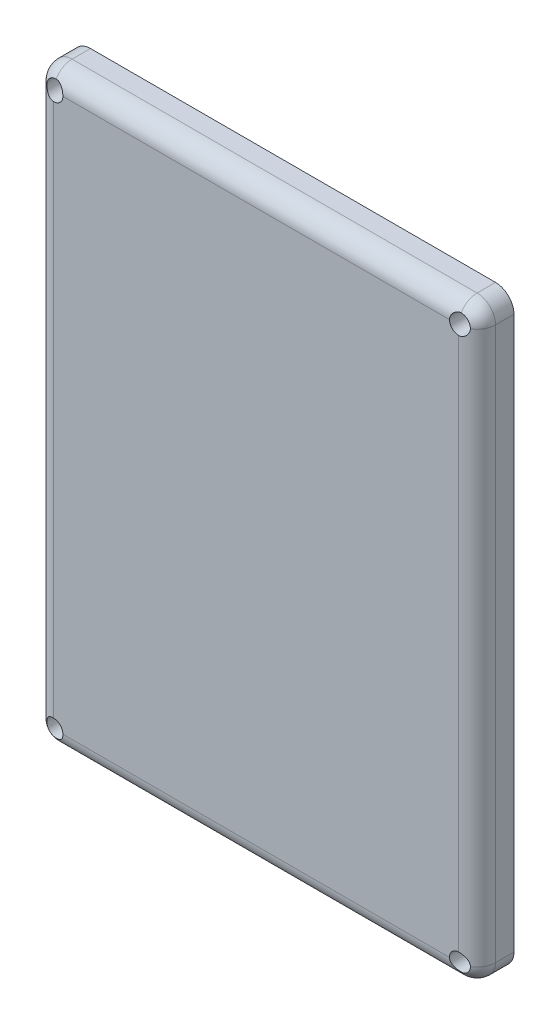
from build123d import *

# Parameters (mm, degrees)
SKETCH1_W           = 120
SKETCH1_H           = 160
BOSS_EXTRUDE1_DEPTH = 10
SKETCH2_W           = 100
SKETCH2_H           = 140
CUT_EXTRUDE1_DEPTH  = 5
FILLET1_R           = 5
FILLET2_R           = 5
FILLET3_R           = 5
SKETCH3_R           = 2.5
CUT_EXTRUDE2_DEPTH  = 5
SKETCH4_R           = 2.5
CUT_EXTRUDE3_DEPTH  = 5
SKETCH5_R           = 2.5
CUT_EXTRUDE4_DEPTH  = 5
SKETCH6_R           = 1.5
CUT_EXTRUDE5_DEPTH  = 10


with BuildPart() as part:
    # Sketch1 → Boss-Extrude1 (new body)
    with BuildSketch(Plane.XY):
        with Locations((60, -80)):
            Rectangle(SKETCH1_W, SKETCH1_H)
    extrude(amount=BOSS_EXTRUDE1_DEPTH)

    # Sketch2 → Cut-Extrude1 (cut)
    with BuildSketch(Plane(origin=(0, 0, 0), x_dir=(-1, 0, 0), z_dir=(0, 0, -1))):
        with Locations((-60, -80)):
            Rectangle(SKETCH2_W, SKETCH2_H)
    extrude(amount=-CUT_EXTRUDE1_DEPTH, mode=Mode.SUBTRACT)

    # Fillet1
    fillet1_edges = [part.edges().sort_by_distance(p)[0] for p in [
        (10, -10, 2.5),
    ]]
    fillet(fillet1_edges, radius=FILLET1_R)

    # Fillet2
    fillet2_edges = [part.edges().sort_by_distance(p)[0] for p in [
        (110, -150, 2.5),
        (110, -10, 2.5),
        (10, -150, 2.5),
    ]]
    fillet(fillet2_edges, radius=FILLET2_R)

    # Fillet3
    fillet3_edges = [part.edges().sort_by_distance(p)[0] for p in [
        (120, -80, 10),
        (60, 0, 10),
        (0, -80, 10),
        (60, -160, 10),
        (0, 0, 5),
        (120, 0, 5),
        (120, -160, 5),
        (0, -160, 5),
    ]]
    fillet(fillet3_edges, radius=FILLET3_R)

    # Sketch3 → Cut-Extrude2 (cut)
    with BuildSketch(Plane.XY.offset(10)):
        with Locations((115, -5)):
            Circle(SKETCH3_R)
    extrude(amount=-CUT_EXTRUDE2_DEPTH, mode=Mode.SUBTRACT)

    # Sketch4 → Cut-Extrude3 (cut)
    with BuildSketch(Plane.XY.offset(10)):
        with Locations((5, -5)):
            Circle(SKETCH4_R)
    extrude(amount=-CUT_EXTRUDE3_DEPTH, mode=Mode.SUBTRACT)

    # Sketch5 → Cut-Extrude4 (cut)
    with BuildSketch(Plane.XY.offset(10)):
        with Locations((5, -155)):
            Circle(SKETCH5_R)
        with Locations((115, -155)):
            Circle(SKETCH5_R)
    extrude(amount=-CUT_EXTRUDE4_DEPTH, mode=Mode.SUBTRACT)

    # Sketch6 → Cut-Extrude5 (cut)
    with BuildSketch(Plane.XY.offset(5)):
        with Locations((5, -5)):
            Circle(SKETCH6_R)
        with Locations((115, -5)):
            Circle(SKETCH6_R)
        with Locations((115, -155)):
            Circle(SKETCH6_R)
        with Locations((5, -155)):
            Circle(SKETCH6_R)
    extrude(amount=-CUT_EXTRUDE5_DEPTH, mode=Mode.SUBTRACT)


solid = part.part
